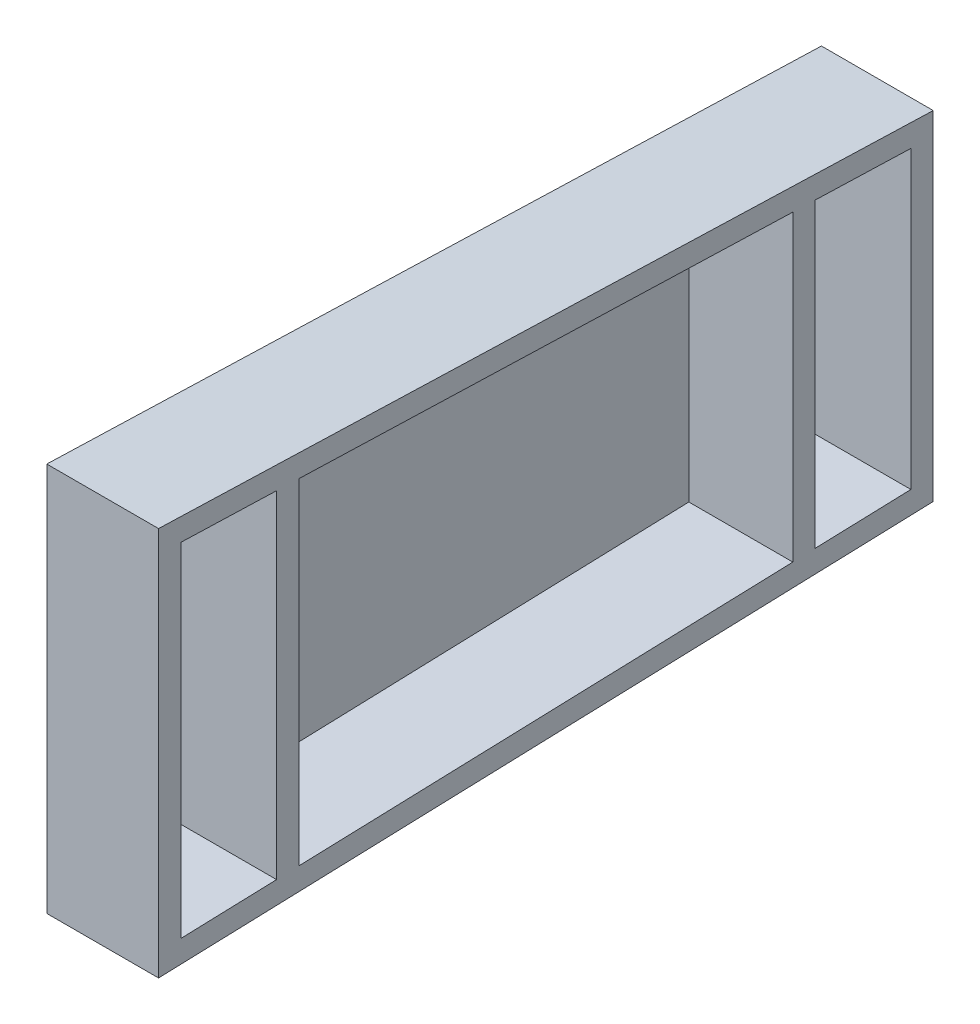
from build123d import *

# Parameters (mm, degrees)
BOSS_EXTRUDE1_DEPTH = 3
BOSS_EXTRUDE2_DEPTH = 40


with BuildPart() as part:
    # Sketch1 → Boss-Extrude1 (new body)
    with BuildSketch(Plane(origin=(0, 0, 0), x_dir=(0, 0, -1), z_dir=(1, 0, 0))):
        Polygon((0, 74.865), (0, -74.865), (298, -65.13), (298, 65.13), align=None)
    extrude(amount=BOSS_EXTRUDE1_DEPTH)

    # Sketch2 → Boss-Extrude2 (add)
    with BuildSketch(Plane(origin=(3, 0, 0), x_dir=(0, 0, -1), z_dir=(1, 0, 0))):
        Polygon((0, 74.865), (298, 65.13), (298, 56.53), (298, 0), (289.4, 0), (289.4, 56.810942953), (252.6, 58.01311745), (252.6, 0), (244, 0), (244, 58.294060403), (54, 64.500939597), (54, 0), (45.4, 0), (45.4, 64.78188255), (8.6, 65.984057047), (8.6, 0), (0, 0), (0, 66.265), align=None)
    boss_extrude2 = extrude(amount=BOSS_EXTRUDE2_DEPTH)

    # Mirror1: Boss-Extrude2 across plane
    add(boss_extrude2.mirror(Plane(origin=(43, 0, -45.4), x_dir=(0, 0, 1), z_dir=(0, 1, 0))))


solid = part.part
